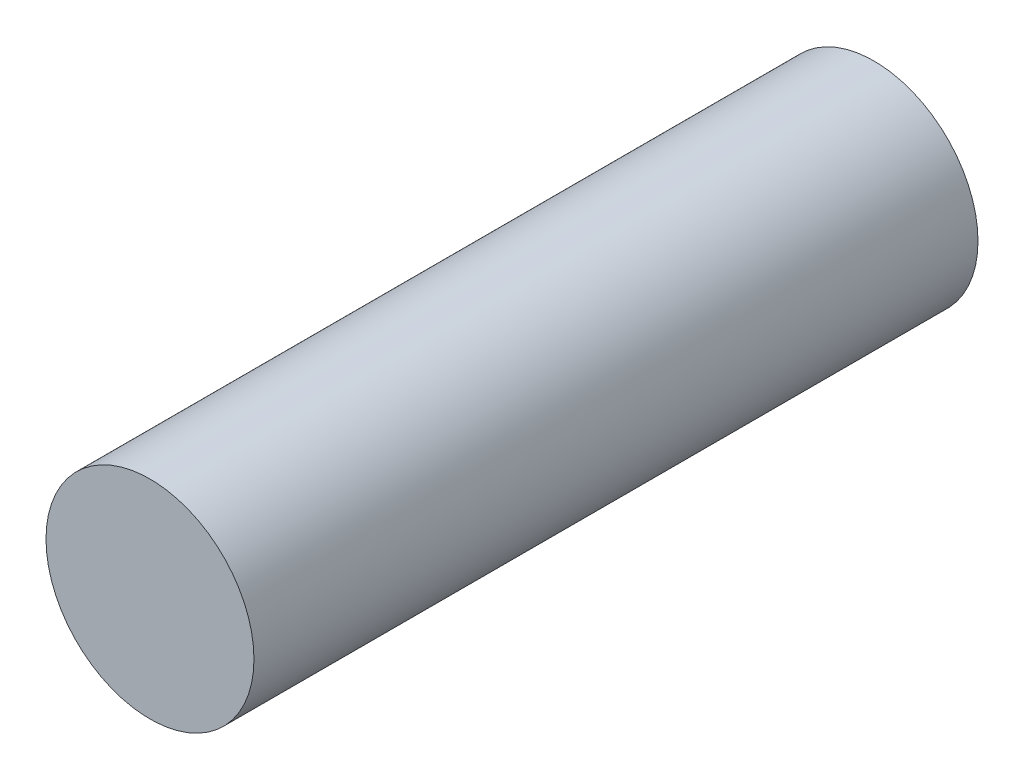
from build123d import *

# Parameters (mm, degrees)
SKETCH1_R           = 7.2517
BOSS_EXTRUDE1_DEPTH = 25.2476


with BuildPart() as part:
    # Sketch1 → Boss-Extrude1 (new body, symmetric)
    with BuildSketch(Plane.XY):
        Circle(SKETCH1_R)
    extrude(amount=BOSS_EXTRUDE1_DEPTH, both=True)


solid = part.part
